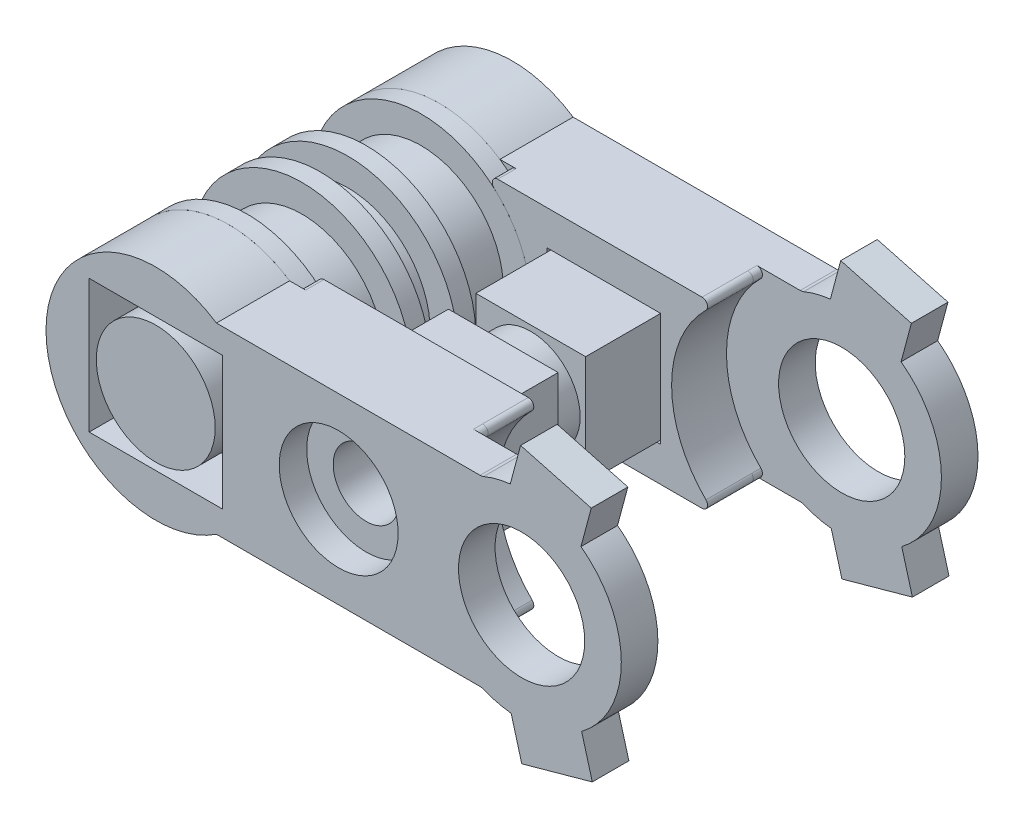
from build123d import *
from build123d.topology import SkipClean

# Parameters (mm, degrees)
SKETCH_1_R               = 4.5
EXTRUDE_1_DEPTH          = 3
SKETCH_2_R               = 6
EXTRUDE_2_DEPTH          = 1
EXTRUDE_START            = 1.5
SKETCH_3_R               = 4.5
EXTRUDE_3_DEPTH          = 1.5
SKETCH_4_R               = 6.000000000000001
EXTRUDE_4_DEPTH          = 1
EXTRUDE_START_2          = 3
SKETCH_5_R               = 4.5
EXTRUDE_5_DEPTH          = 3
SKETCH_6_R               = 6.000000000000001
EXTRUDE_6_DEPTH          = 1
EXTRUDE_START_3          = 1
SKETCH_7_R               = 6.000000000000001
EXTRUDE_7_DEPTH          = 1
EXTRUDE_10_DEPTH         = 1.5
SKETCH_11_R              = 3.25
EXTRUDE_11_DEPTH         = 2.5
EXTRUDE_12_DEPTH         = 1.5
EXTRUDE_13_DEPTH         = 0.5
FILLET_9_R               = 0.3
SKETCH_14_R              = 3.450000000000003
EXTRUDE_14_DEPTH         = 2
EXTRUDE_15_DEPTH         = 1
SKETCH_16_R              = 1.799999999999999
CUT_EXTRUDE_1_DEPTH      = 33.61828474950821
CUT_EXTRUDE_2_DEPTH      = 2
EXTRUDE_16_DEPTH         = 11.5
SKETCH_19_R              = 1.799999999999999
CUT_EXTRUDE_3_DEPTH      = 30.89903844607716
CUT_EXTRUDE_4_DEPTH      = 0.75
CUT_EXTRUDE_4_DEPTH_BACK = 0.75
SKETCH_20_R              = 2.6999999999999993
SKETCH_21_R              = 3.2500000000000027
CUT_EXTRUDE_5_DEPTH      = 1.5
CUT_EXTRUDE_6_DEPTH      = 1
EXTRUDE_17_DEPTH         = 2
EXTRUDE_18_DEPTH         = 2
EXTRUDE_19_DEPTH         = 2.5
EXTRUDE_START_4          = 2.5
EXTRUDE_20_DEPTH         = 2.5


with BuildPart() as part:
    # ｽｹｯﾁ1 → ﾎﾞｽ - 押し出し1 (new body)
    with BuildSketch(Plane.XY):
        Circle(SKETCH_1_R)
    extrude(amount=EXTRUDE_1_DEPTH)

    # ｽｹｯﾁ2 → ﾎﾞｽ - 押し出し2 (add)
    with BuildSketch(Plane(origin=(0, 0, 0), x_dir=(-1, 0, 0), z_dir=(0, 0, -1))):
        Circle(SKETCH_2_R)
    extrude(amount=EXTRUDE_2_DEPTH)

    # ｽｹｯﾁ3 → ﾎﾞｽ - 押し出し3 (add)
    with BuildSketch(Plane(origin=(0, 0, -1), x_dir=(-1, 0, 0), z_dir=(0, 0, -1)).offset(EXTRUDE_START)):
        with Locations(Location((0, 0, 0), (0, 0, 180))):
            Circle(SKETCH_3_R)
    extrude(amount=-EXTRUDE_3_DEPTH)

    # ｽｹｯﾁ4 → ﾎﾞｽ - 押し出し4 (add)
    with BuildSketch(Plane(origin=(0, 0, -2.5), x_dir=(-1, 0, 0), z_dir=(0, 0, -1))):
        Circle(SKETCH_4_R)
    extrude(amount=EXTRUDE_4_DEPTH)

    # ｽｹｯﾁ5 → ﾎﾞｽ - 押し出し5 (add)
    with BuildSketch(Plane(origin=(0, 0, -3.5), x_dir=(-1, 0, 0), z_dir=(0, 0, -1)).offset(EXTRUDE_START_2)):
        with Locations(Location((0, 0, 0), (0, 0, 180))):
            Circle(SKETCH_5_R)
    extrude(amount=-EXTRUDE_5_DEPTH)

    # ｽｹｯﾁ6 → ﾎﾞｽ - 押し出し6 (add)
    with BuildSketch(Plane(origin=(0, 0, -6.500000000000001), x_dir=(-1, 0, 0), z_dir=(0, 0, -1))):
        Circle(SKETCH_6_R)
    extrude(amount=EXTRUDE_6_DEPTH)

    # ｽｹｯﾁ7 → ﾎﾞｽ - 押し出し7 (add)
    with BuildSketch(Plane.XY.offset(3).offset(EXTRUDE_START_3)):
        with Locations(Location((0, 0, 0), (0, 0, 180))):
            Circle(SKETCH_7_R)
    extrude(amount=-EXTRUDE_7_DEPTH)

    # ｽｹｯﾁ10 → ﾎﾞｽ - 押し出し10 (add)
    with BuildSketch(Plane.XY.offset(4)):
        Polygon((3.4999999999999996, -3.5), (-3.5000000000000004, -3.500000000000001), (-3.5000000000000004, 3.5000000000000004), (3.4999999999999996, 3.5), align=None)
    extrude_10 = extrude(amount=EXTRUDE_10_DEPTH)

    # ｽｹｯﾁ11 → ﾎﾞｽ - 押し出し11 (add)
    with BuildSketch(Plane.XY.offset(5.5)):
        Circle(SKETCH_11_R)
    extrude_11 = extrude(amount=EXTRUDE_11_DEPTH)

    # ﾐﾗｰ1: ﾎﾞｽ - 押し出し10, ﾎﾞｽ - 押し出し11 across plane
    add(extrude_10.mirror(Plane.XY.offset(-1.7500000000000002)))
    add(extrude_11.mirror(Plane.XY.offset(-1.7500000000000002)))


with BuildPart() as body_2:
    # ｽｹｯﾁ12 → ﾎﾞｽ - 押し出し12 (new body)
    with BuildSketch(Plane.XY.offset(4)):
        with BuildLine():
            Line((3.3166247903554016, 5), (16.167246420652642, 5))
            ThreePointArc((16.167246420652642, 5), (13.700000000000001, 3.57e-15), (16.16724642065264, -5))
            Line((16.16724642065264, -5), (3.3166247903553985, -5.000000000000003))
            ThreePointArc((3.3166247903553985, -5.000000000000003), (-6.000000000000001, 7.3e-16), (3.3166247903554016, 5))
        make_face()
        Polygon((3.6399999999999997, -3.64), (3.6399999999999997, 3.64), (-3.6400000000000006, 3.6400000000000006), (-3.6400000000000006, -3.640000000000001), align=None, mode=Mode.SUBTRACT)
    extrude(amount=EXTRUDE_12_DEPTH)

    # ｽｹｯﾁ13 → ﾎﾞｽ - 押し出し13 (add)
    with BuildSketch(Plane.XY.offset(5.5)):
        with BuildLine():
            Line((15.366426864718767, 5.000000000000001), (3.71350238992787, 4.999999999999999))
            ThreePointArc((3.71350238992787, 4.999999999999999), (3.4301142319534543, 4.798443648448575), (3.5275172952737197, 4.464607679465777))
            ThreePointArc((3.5275172952737197, 4.464607679465777), (5.69, 3.16e-15), (3.527517295273725, -4.464607679465773))
            ThreePointArc((3.527517295273725, -4.464607679465773), (3.4301142319534588, -4.798443648448569), (3.713502389927875, -4.9999999999999964))
            Line((3.713502389927875, -4.9999999999999964), (15.366426864718758, -4.999999999999996))
            ThreePointArc((15.366426864718758, -4.999999999999996), (15.643997494550977, -4.813818036595895), (15.57704382541336, -4.486363636363631))
            ThreePointArc((15.57704382541336, -4.486363636363631), (13.7, 6.37e-15), (15.577043825413366, 4.486363636363639))
            ThreePointArc((15.577043825413366, 4.486363636363639), (15.643997494550984, 4.813818036595901), (15.366426864718767, 5.000000000000001))
        make_face()
    extrude(amount=EXTRUDE_13_DEPTH)

    # ﾌｨﾚｯﾄ9
    fillet_9_edges = [body_2.edges().sort_by_distance(p)[0] for p in [
        (16.16724642065264, -5.000000000000001, 4.75),
        (16.167246420652642, 5, 4.75),
    ]]
    fillet(fillet_9_edges, radius=FILLET_9_R)

    # ｽｹｯﾁ14 → ﾎﾞｽ - 押し出し14 (add)
    with BuildSketch(Plane.XY.offset(6)):
        with BuildLine():
            Line((3.71350238992787, 5), (17.73008810743677, 5))
            ThreePointArc((17.73008810743677, 5), (17.827318665969592, 5.00954488636839), (17.920837005971492, 5.03781512605042))
            ThreePointArc((17.920837005971492, 5.03781512605042), (25.45, 2.42e-15), (17.920837005971496, -5.037815126050422))
            ThreePointArc((17.920837005971496, -5.037815126050422), (17.827318665969596, -5.009544886368393), (17.730088107436774, -5.000000000000003))
            Line((17.730088107436774, -5.000000000000003), (3.713502389927875, -5.000000000000003))
            ThreePointArc((3.713502389927875, -5.000000000000003), (3.430114231953458, -4.79844364844857), (3.5275172952737246, -4.4646076794657725))
            ThreePointArc((3.5275172952737246, -4.4646076794657725), (5.69, 3.16e-15), (3.52751729527372, 4.464607679465777))
            ThreePointArc((3.52751729527372, 4.464607679465777), (3.4301142319534534, 4.798443648448575), (3.71350238992787, 5))
        make_face()
        with Locations((20, 0)):
            Circle(SKETCH_14_R, mode=Mode.SUBTRACT)
    extrude(amount=EXTRUDE_14_DEPTH)

    # ｽｹｯﾁ15 → ﾎﾞｽ - 押し出し15 (add)
    with BuildSketch(Plane(origin=(0, 0, 4), x_dir=(-1, 0, 0), z_dir=(0, 0, -1))):
        with BuildLine():
            Line((-15.366426864718765, 5), (-4.195235392680607, 5.000000000000001))
            ThreePointArc((-4.195235392680607, 5.000000000000001), (-3.9149294373899135, 4.806904496764971), (-3.9954622787434353, 4.476190476190477))
            ThreePointArc((-3.9954622787434353, 4.476190476190477), (-6.000000000000001, 7.3e-16), (-3.9954622787434353, -4.476190476190477))
            ThreePointArc((-3.9954622787434353, -4.476190476190477), (-3.9149294373899135, -4.806904496764971), (-4.195235392680607, -5.000000000000001))
            Line((-4.195235392680607, -5.000000000000001), (-15.366426864718763, -5))
            ThreePointArc((-15.366426864718763, -5), (-15.643997494550984, -4.813818036595896), (-15.577043825413359, -4.48636363636363))
            ThreePointArc((-15.577043825413359, -4.48636363636363), (-13.700000000000001, 4.2e-15), (-15.577043825413364, 4.486363636363636))
            ThreePointArc((-15.577043825413364, 4.486363636363636), (-15.643997494550984, 4.813818036595898), (-15.366426864718765, 5))
        make_face()
    extrude(amount=EXTRUDE_15_DEPTH)


with BuildPart() as body_3:
    # ﾐﾗｰ2: mirrored copy
    add(body_2.part.mirror(Plane.XY.offset(-1.7500000000000002)))


with BuildPart() as cut_extrude_1_tool:
    # ｽｹｯﾁ16 → ｶｯﾄ - 押し出し1 (new, through all)
    with BuildSketch(Plane.XY.offset(8)):
        with Locations((10, 0)):
            Circle(SKETCH_16_R)
    extrude(amount=-CUT_EXTRUDE_1_DEPTH)


with BuildPart() as body_2_1:
    add(body_2.part)

    # ｶｯﾄ - 押し出し1: cut by cut_extrude_1_tool
    add(cut_extrude_1_tool.part, mode=Mode.SUBTRACT)

    # ｽｹｯﾁ18 → ﾎﾞｽ - 押し出し16 (add)
    with BuildSketch(Plane(origin=(0, 0, 3), x_dir=(-1, 0, 0), z_dir=(0, 0, -1))):
        Polygon((-7.000000000000002, 2.9999999999999996), (-13.000000000000002, 2.9999999999999987), (-13.000000000000002, -2.9999999999999996), (-7.000000000000002, -2.999999999999999), align=None)
    extrude(amount=EXTRUDE_16_DEPTH)

    # ｽｹｯﾁ19 → ｶｯﾄ - 押し出し3 (cut, through all)
    with BuildSketch(Plane.XY.offset(3)):
        with Locations((10, 0)):
            Circle(SKETCH_19_R)
    extrude(amount=-CUT_EXTRUDE_3_DEPTH, mode=Mode.SUBTRACT)

    # ｽｹｯﾁ20 → ｶｯﾄ - 押し出し4 (cut, two sides: drawn at the far end of the back side and taken through both)
    with BuildSketch(Plane.XY.offset(-1.7500000000000002).offset(-CUT_EXTRUDE_4_DEPTH_BACK)):
        Polygon((13.000000000000002, 2.9999999999999987), (7.000000000000002, 2.9999999999999996), (7.000000000000002, -2.999999999999999), (13.000000000000002, -2.9999999999999996), align=None)
        with Locations((10, 0)):
            Circle(SKETCH_20_R, mode=Mode.SUBTRACT)
    extrude(amount=CUT_EXTRUDE_4_DEPTH + CUT_EXTRUDE_4_DEPTH_BACK, mode=Mode.SUBTRACT)

    # ｽｹｯﾁ21 → ｶｯﾄ - 押し出し5 (cut)
    with BuildSketch(Plane.XY.offset(8)):
        with Locations((10, 0)):
            Circle(SKETCH_21_R)
    extrude(amount=-CUT_EXTRUDE_5_DEPTH, mode=Mode.SUBTRACT)

    # ｽｹｯﾁ23 → ﾎﾞｽ - 押し出し17 (add)
    with BuildSketch(Plane.XY.offset(8)):
        Polygon((19.01283786204607, 4.043267356160141), (22.87654116720234, 3.007991175750056), (23.808289729571417, 6.485324150390701), (19.944586424415146, 7.520600330800787), align=None)
        Polygon((20.01021732015007, -7.520797537919029), (19.048159166268373, -4.051727906367982), (22.90268097910287, -2.982774402054983), (23.86473913298457, -6.451844033606031), align=None)
    extrude(amount=-EXTRUDE_17_DEPTH)

    # ｽｹｯﾁ26 → ﾎﾞｽ - 押し出し20 (add)
    with SkipClean():  # the faces are left unmerged after this step: merging them gives an invalid solid
        with BuildSketch(Plane.XY.offset(5.5).offset(EXTRUDE_START_4)):
            with BuildLine():
                Line((3.3166247903554025, -5), (3.713502389927875, -4.999999999999999))
                ThreePointArc((3.713502389927875, -4.999999999999999), (3.430114231953457, -4.798443648448569), (3.527517295273725, -4.464607679465772))
                ThreePointArc((3.527517295273725, -4.464607679465772), (5.6899999999999995, 3.79e-15), (3.52751729527372, 4.464607679465777))
                ThreePointArc((3.52751729527372, 4.464607679465777), (3.4301142319534526, 4.798443648448575), (3.71350238992787, 5.000000000000001))
                Line((3.71350238992787, 5.000000000000001), (3.316624790355401, 5.000000000000001))
                ThreePointArc((3.316624790355401, 5.000000000000001), (-6.000000000000002, 7.3e-16), (3.3166247903554025, -5))
            make_face()
            Polygon((-3.6400000000000006, 3.6400000000000006), (-3.6400000000000006, -3.640000000000001), (3.6399999999999997, -3.64), (3.6399999999999997, 3.64), align=None, mode=Mode.SUBTRACT)
        extrude(amount=-EXTRUDE_20_DEPTH)


with BuildPart() as body_3_1:
    add(body_3.part)

    # ｶｯﾄ - 押し出し1: cut by cut_extrude_1_tool
    add(cut_extrude_1_tool.part, mode=Mode.SUBTRACT)

    # ｽｹｯﾁ17 → ｶｯﾄ - 押し出し2 (cut)
    with BuildSketch(Plane.XY.offset(-6.500000000000001)):
        Polygon((13.100000000000001, -3.0999999999999996), (6.900000000000001, -3.1000000000000005), (6.900000000000001, 3.0999999999999996), (13.100000000000001, 3.1000000000000005), align=None)
    extrude(amount=-CUT_EXTRUDE_2_DEPTH, mode=Mode.SUBTRACT)

    # ｽｹｯﾁ22 → ｶｯﾄ - 押し出し6 (cut)
    with BuildSketch(Plane(origin=(0, 0, -11.5), x_dir=(-1, 0, 0), z_dir=(0, 0, -1))):
        Polygon((-11.674315780649914, 2.8999999999999995), (-13.348631561299829, 1e-17), (-11.674315780649913, -2.900000000000001), (-8.325684219350087, -2.9000000000000004), (-6.651368438700171, -8.7e-16), (-8.325684219350087, 2.9), align=None)
    extrude(amount=-CUT_EXTRUDE_6_DEPTH, mode=Mode.SUBTRACT)

    # ｽｹｯﾁ24 → ﾎﾞｽ - 押し出し18 (add)
    with BuildSketch(Plane(origin=(0, 0, -11.5), x_dir=(-1, 0, 0), z_dir=(0, 0, -1))):
        Polygon((-22.87654116720234, 3.007991175750056), (-19.01283786204607, 4.043267356160141), (-19.944586424415146, 7.520600330800787), (-23.808289729571417, 6.485324150390701), align=None)
        Polygon((-20.01021732015007, -7.520797537919029), (-19.048159166268373, -4.051727906367982), (-22.90268097910287, -2.982774402054983), (-23.86473913298457, -6.451844033606031), align=None)
    extrude(amount=-EXTRUDE_18_DEPTH)

    # ｽｹｯﾁ25 → ﾎﾞｽ - 押し出し19 (add)
    with BuildSketch(Plane(origin=(0, 0, -9.000000000000002), x_dir=(-1, 0, 0), z_dir=(0, 0, -1))):
        with BuildLine():
            Line((-3.713502389927875, -4.999999999999999), (-3.3166247903554025, -5))
            ThreePointArc((-3.3166247903554025, -5), (6.000000000000002, -2.66e-15), (-3.3166247903554016, 5))
            Line((-3.3166247903554016, 5), (-3.71350238992787, 5.000000000000001))
            ThreePointArc((-3.71350238992787, 5.000000000000001), (-3.430114231953452, 4.798443648448575), (-3.52751729527372, 4.464607679465777))
            ThreePointArc((-3.52751729527372, 4.464607679465777), (-5.690000000000001, 3.22e-15), (-3.5275172952737224, -4.46460767946577))
            ThreePointArc((-3.5275172952737224, -4.46460767946577), (-3.430114231953454, -4.798443648448571), (-3.713502389927875, -4.999999999999999))
        make_face()
        Polygon((3.6400000000000006, 3.6400000000000006), (3.6400000000000006, -3.640000000000001), (-3.6399999999999997, -3.64), (-3.6399999999999997, 3.64), align=None, mode=Mode.SUBTRACT)
    extrude(amount=EXTRUDE_19_DEPTH)


solid = Compound([part.part, body_2_1.part, body_3_1.part])
